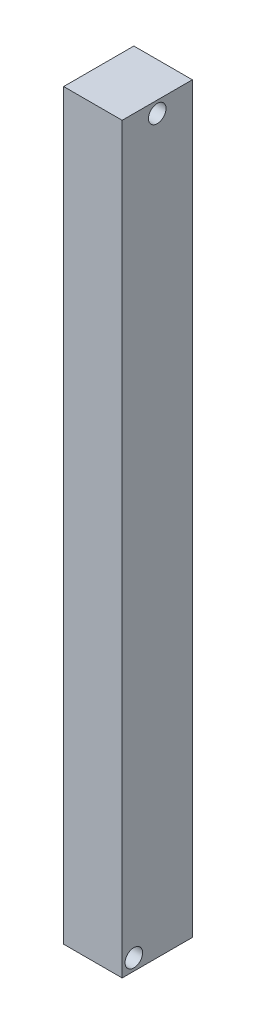
from build123d import *

# Parameters (mm, degrees)
SKETCH1_W           = 127
SKETCH1_H           = 152.4
BOSS_EXTRUDE2_DEPTH = 1612.9
SKETCH2_R           = 19.05
CUT_EXTRUDE1_DEPTH  = 152.4
SKETCH3_R           = 19.05
CUT_EXTRUDE2_DEPTH  = 152.4


with BuildPart() as part:
    # Sketch1 → Boss-Extrude2 (new body)
    with BuildSketch(Plane(origin=(0, 0, 0), x_dir=(1, 0, 0), z_dir=(0, 1, 0))):
        with Locations((63.5, 76.2)):
            Rectangle(SKETCH1_W, SKETCH1_H)
    extrude(amount=BOSS_EXTRUDE2_DEPTH)

    # Sketch2 → Cut-Extrude1 (cut)
    with BuildSketch(Plane(origin=(127, 0, 0), x_dir=(0, 0, -1), z_dir=(1, 0, 0))):
        with Locations((25.4, 25.4)):
            Circle(SKETCH2_R)
    extrude(amount=-CUT_EXTRUDE1_DEPTH, mode=Mode.SUBTRACT)

    # Sketch3 → Cut-Extrude2 (cut)
    with BuildSketch(Plane(origin=(127, 0, 0), x_dir=(0, 0, -1), z_dir=(1, 0, 0))):
        with Locations((76.2, 1587.5)):
            Circle(SKETCH3_R)
    extrude(amount=-CUT_EXTRUDE2_DEPTH, mode=Mode.SUBTRACT)


solid = part.part
